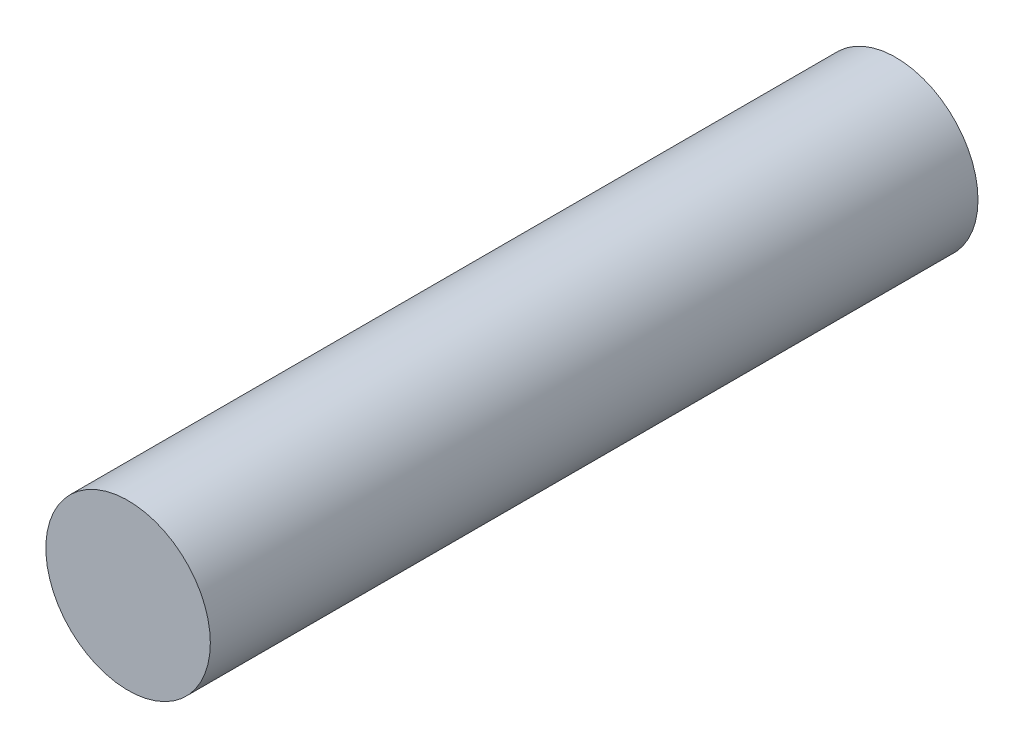
from build123d import *

# Parameters (mm, degrees)
CROQUIS5_R              = 3
SALIENTE_EXTRUIR5_DEPTH = 28
ESCALA1_SCALE           = 7
ESCALA2_SCALE           = 7


with BuildPart() as part:
    # Croquis5 → Saliente-Extruir5 (new body)
    with BuildSketch(Plane.XY):
        Circle(CROQUIS5_R)
    extrude(amount=SALIENTE_EXTRUIR5_DEPTH)


with BuildPart() as part_1:
    # Escala1: scaled about (0, 0, 14)
    add(part.part.scale(ESCALA1_SCALE).moved(Location((0, 0, -84))))


with BuildPart() as part_2:
    # Escala2: scaled about (0, 0, 14)
    add(part_1.part.scale(ESCALA2_SCALE).moved(Location((0, 0, -84))))


solid = part_2.part
